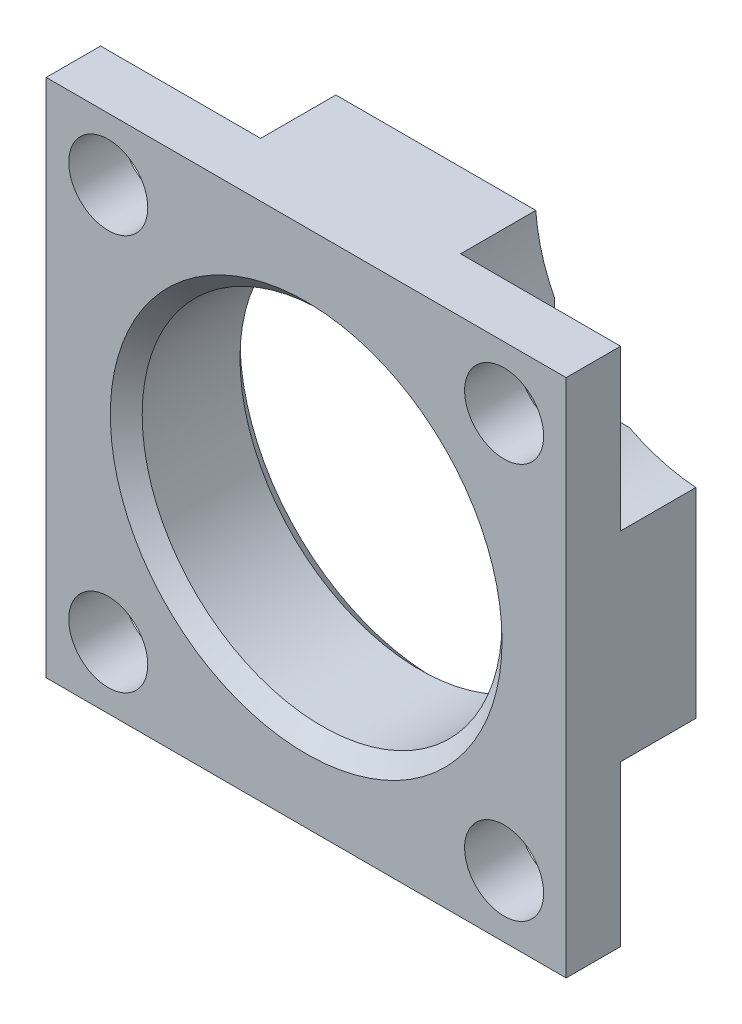
from build123d import *

# Parameters (mm, degrees)
SKETCH1_W          = 38.1
SKETCH1_H          = 38.1
SKETCH1_R          = 13.183
EXTRUDE1_DEPTH     = 9.4996
CUT_EXTRUDE1_DEPTH = 5.5118
HOLE1_D            = 5.7912
HOLE1_DEPTH        = 3.9878


with BuildPart() as part:
    # Sketch1 → Extrude1 (new body)
    with BuildSketch(Plane.XY):
        Rectangle(SKETCH1_W, SKETCH1_H)
        Circle(SKETCH1_R, mode=Mode.SUBTRACT)
    extrude(amount=-EXTRUDE1_DEPTH)

    # Sketch2 → Cut-Extrude1 (cut)
    with BuildSketch(Plane(origin=(0, 0, -9.4996), x_dir=(1, 0, 0), z_dir=(0, 0, -1))):
        with BuildLine():
            Line((19.05, 19.05), (19.05, 7.324620334))
            ThreePointArc((19.05, 7.324620334), (11.009543879, 11.009543879), (7.324620334, 19.05))
            Line((7.324620334, 19.05), (19.05, 19.05))
        make_face()
        with BuildLine():
            Line((19.05, -19.05), (19.05, -7.324620334))
            ThreePointArc((19.05, -7.324620334), (11.009543879, -11.009543879), (7.324620334, -19.05))
            Line((7.324620334, -19.05), (19.05, -19.05))
        make_face()
        with BuildLine():
            Line((-19.05, -19.05), (-7.324620334, -19.05))
            ThreePointArc((-7.324620334, -19.05), (-11.009543879, -11.009543879), (-19.05, -7.324620334))
            Line((-19.05, -7.324620334), (-19.05, -19.05))
        make_face()
        with BuildLine():
            Line((-19.05, 19.05), (-7.324620334, 19.05))
            ThreePointArc((-7.324620334, 19.05), (-11.009543879, 11.009543879), (-19.05, 7.324620334))
            Line((-19.05, 7.324620334), (-19.05, 19.05))
        make_face()
    extrude(amount=-CUT_EXTRUDE1_DEPTH, mode=Mode.SUBTRACT)

    # Hole1
    with Locations(Plane(origin=(0, 0, -3.9878), x_dir=(-1, 0, 0), z_dir=(0, 0, -1))):
        with Locations((14.5034, 14.5034), (14.5034, -14.5034), (-14.5034, 14.5034), (-14.5034, -14.5034)):
            Hole(HOLE1_D / 2, depth=HOLE1_DEPTH)

    # Sketch5 → Cut-Revolve1 (revolve, cut)
    with BuildSketch(Plane(origin=(0, 0, 0), x_dir=(0, 0, -1), z_dir=(1, 0, 0)), mode=Mode.PRIVATE) as cut_revolve1_sk:
        Polygon((9.4996, 13.183), (9.4996, 14.351), (8.3316, 13.183), align=None)
        Polygon((1.168, 13.183), (0, 13.183), (0, 14.351), align=None)
    revolve(cut_revolve1_sk.sketch.rotate(Axis((0, 0, 7.380919067), (0, 0, -1)), 90), axis=Axis((0, 0, 7.380919067), (0, 0, -1)), mode=Mode.SUBTRACT)  # turned: the seam where the file's is

    # Sketch6 → Cut-Revolve2 (revolve, cut)
    with BuildSketch(Plane(origin=(0, 0, 0), x_dir=(1, 0, 0), z_dir=(0, 1, 0))):
        Polygon((15.875, 9.4996), (16.256, 9.1186), (16.637, 9.4996), align=None)
    revolve(axis=Axis((0, 0, 0), (0, 0, -1)), mode=Mode.SUBTRACT)


solid = part.part
